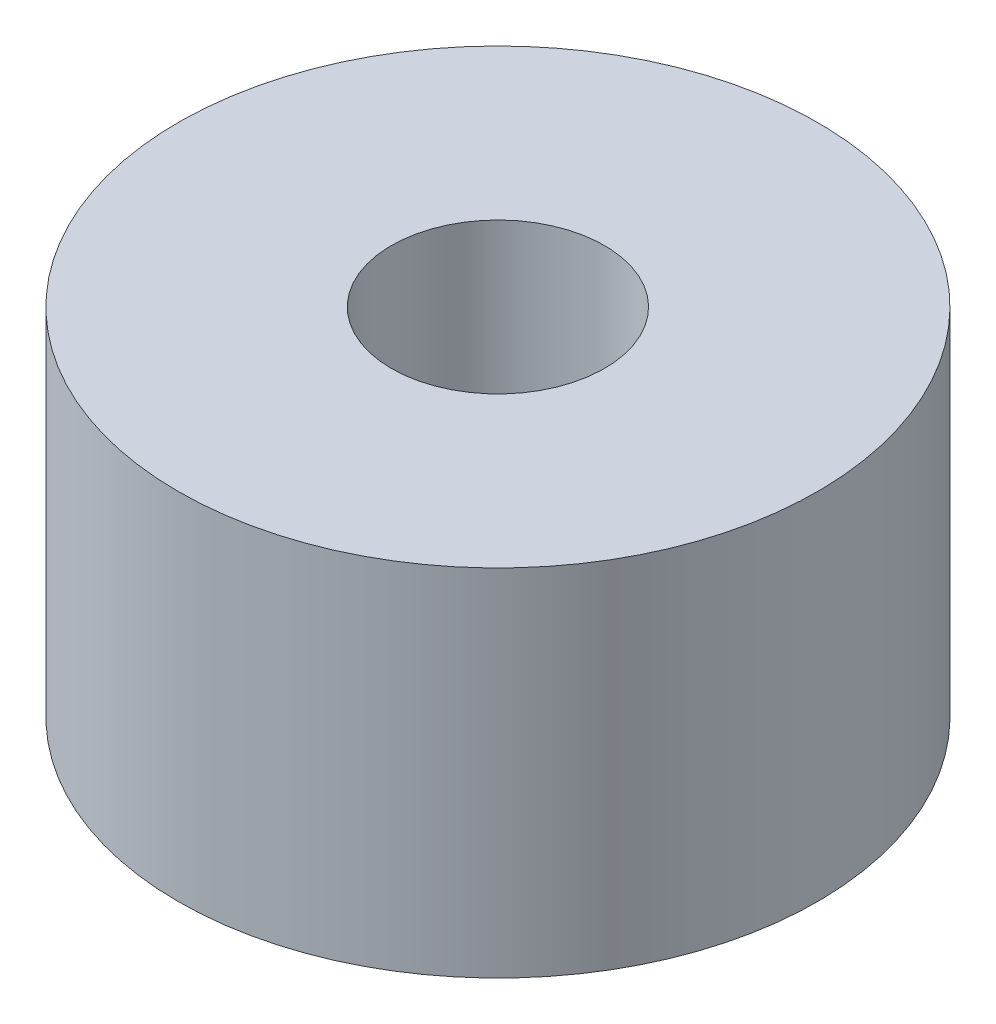
from build123d import *

# Parameters (mm, degrees)
SKETCH1_R           = 4.5
SKETCH1_R_2         = 1.5
BOSS_EXTRUDE1_DEPTH = 5


with BuildPart() as part:
    # Sketch1 → Boss-Extrude1 (new body)
    with BuildSketch(Plane(origin=(0, 0, 0), x_dir=(1, 0, 0), z_dir=(0, 1, 0))):
        Circle(SKETCH1_R)
        Circle(SKETCH1_R_2, mode=Mode.SUBTRACT)
    extrude(amount=BOSS_EXTRUDE1_DEPTH)


solid = part.part
